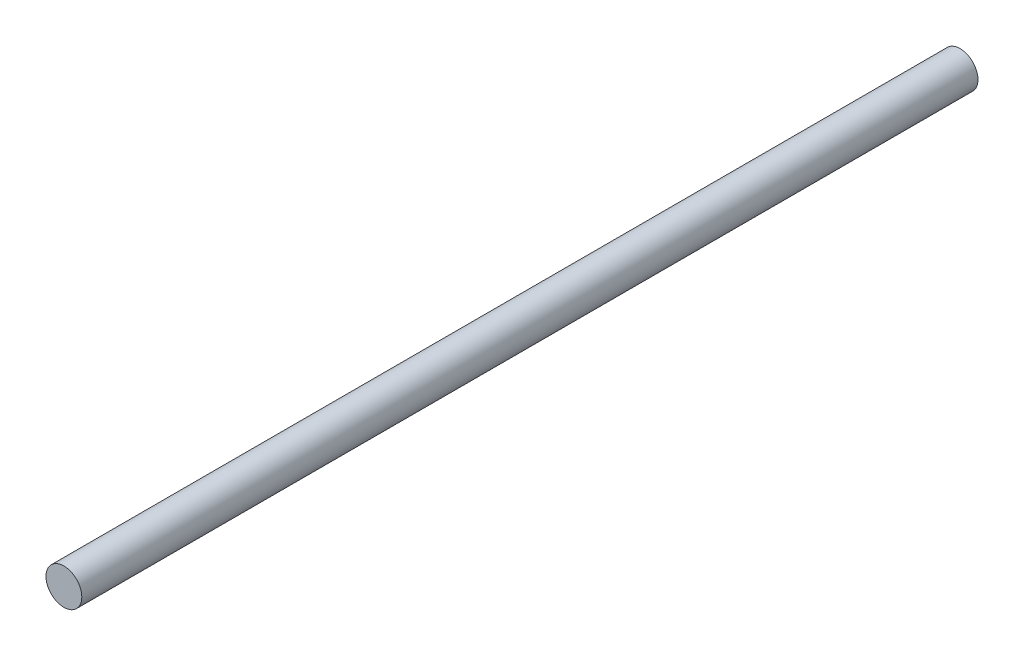
from build123d import *

# Parameters (mm, degrees)
CROQUIS1_R              = 2
SALIENTE_EXTRUIR1_DEPTH = 100


with BuildPart() as part:
    # Croquis1 → Saliente-Extruir1 (new body)
    with BuildSketch(Plane.XY):
        Circle(CROQUIS1_R)
    extrude(amount=SALIENTE_EXTRUIR1_DEPTH)


solid = part.part
